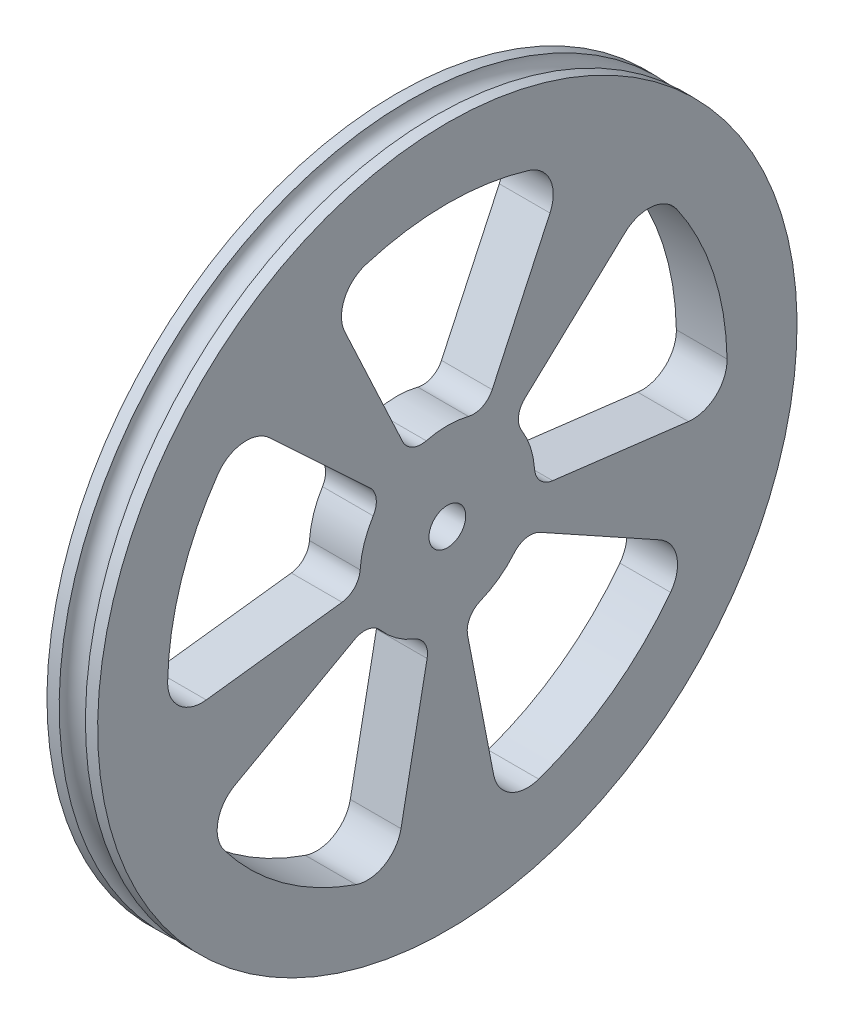
from build123d import *

# Parameters (mm, degrees)
CUT_EXTRUDE1_DEPTH = 8.366
FILLET1_R          = 5
FILLET2_R          = 5
FILLET3_R          = 5
FILLET4_R          = 5
FILLET5_R          = 5
FILLET6_R          = 5
FILLET7_R          = 5
FILLET8_R          = 5
FILLET9_R          = 5
FILLET10_R         = 5
FILLET11_R         = 3
FILLET12_R         = 3
FILLET13_R         = 3
FILLET14_R         = 3
FILLET15_R         = 3
FILLET16_R         = 3
FILLET17_R         = 3
FILLET18_R         = 3
FILLET19_R         = 3
FILLET20_R         = 3
SKETCH4_R          = 2.667
CUT_EXTRUDE2_DEPTH = 8.366


with BuildPart() as part:
    # Sketch1 → Revolve1 (revolve)
    with BuildSketch(Plane.XY):
        with BuildLine():
            Line((1.905, 50.8), (3.683, 50.8))
            Line((3.683, 50.8), (3.683, 0))
            Line((3.683, 0), (-3.683, 0))
            Line((-3.683, 0), (-3.683, 50.8))
            Line((-3.683, 50.8), (-1.905, 50.8))
            ThreePointArc((-1.905, 50.8), (0, 48.895), (1.905, 50.8))
        make_face()
    revolve(axis=Axis((3.683, 0, 0), (-1, 0, 0)))

    # Sketch2 → Cut-Extrude1 (cut, through all)
    with BuildSketch(Plane(origin=(3.683, 0, 0), x_dir=(0, 0, -1), z_dir=(1, 0, 0))):
        with BuildLine():
            Line((-5.367251924, 11.510108895), (-17.175206157, 36.832348465))
            ThreePointArc((-17.175206157, 36.832348465), (0, 40.64), (17.175206157, 36.832348465))
            Line((17.175206157, 36.832348465), (5.367251924, 11.510108895))
            ThreePointArc((5.367251924, 11.510108895), (0, 12.7), (-5.367251924, 11.510108895))
        make_face()
        with BuildLine():
            Line((9.288192011, 8.661379173), (29.722214434, 27.716413353))
            ThreePointArc((29.722214434, 27.716413353), (38.650936822, 12.558450651), (40.337075603, -4.952770116))
            Line((40.337075603, -4.952770116), (12.605336126, -1.547740661))
            ThreePointArc((12.605336126, -1.547740661), (12.078417757, 3.924515829), (9.288192011, 8.661379173))
        make_face()
        with BuildLine():
            Line((11.107670281, -6.157082177), (35.544544898, -19.702662967))
            ThreePointArc((35.544544898, -19.702662967), (23.887592653, -32.878450651), (7.754477572, -39.893328735))
            Line((7.754477572, -39.893328735), (2.423274241, -12.46666523))
            ThreePointArc((2.423274241, -12.46666523), (7.464872704, -10.274515829), (11.107670281, -6.157082177))
        make_face()
        with BuildLine():
            Line((-2.423274241, -12.46666523), (-7.754477572, -39.893328735))
            ThreePointArc((-7.754477572, -39.893328735), (-23.887592653, -32.878450651), (-35.544544898, -19.702662967))
            Line((-35.544544898, -19.702662967), (-11.107670281, -6.157082177))
            ThreePointArc((-11.107670281, -6.157082177), (-7.464872704, -10.274515829), (-2.423274241, -12.46666523))
        make_face()
        with BuildLine():
            Line((-12.605336126, -1.547740661), (-40.337075603, -4.952770116))
            ThreePointArc((-40.337075603, -4.952770116), (-38.650936822, 12.558450651), (-29.722214434, 27.716413353))
            Line((-29.722214434, 27.716413353), (-9.288192011, 8.661379173))
            ThreePointArc((-9.288192011, 8.661379173), (-12.078417757, 3.924515829), (-12.605336126, -1.547740661))
        make_face()
    extrude(amount=-CUT_EXTRUDE1_DEPTH, mode=Mode.SUBTRACT)

    # Fillet1
    fillet1_edges = [part.edges().sort_by_distance(p)[0] for p in [
        (0, -39.893328735, -7.754477572),
    ]]
    fillet(fillet1_edges, radius=FILLET1_R)

    # Fillet2
    fillet2_edges = [part.edges().sort_by_distance(p)[0] for p in [
        (0, -19.702662967, -35.544544898),
    ]]
    fillet(fillet2_edges, radius=FILLET2_R)

    # Fillet3
    fillet3_edges = [part.edges().sort_by_distance(p)[0] for p in [
        (0, 27.716413353, -29.722214434),
    ]]
    fillet(fillet3_edges, radius=FILLET3_R)

    # Fillet4
    fillet4_edges = [part.edges().sort_by_distance(p)[0] for p in [
        (0, -4.952770116, -40.337075603),
    ]]
    fillet(fillet4_edges, radius=FILLET4_R)

    # Fillet5
    fillet5_edges = [part.edges().sort_by_distance(p)[0] for p in [
        (0, 36.832348465, -17.175206157),
    ]]
    fillet(fillet5_edges, radius=FILLET5_R)

    # Fillet6
    fillet6_edges = [part.edges().sort_by_distance(p)[0] for p in [
        (0, 36.832348465, 17.175206157),
    ]]
    fillet(fillet6_edges, radius=FILLET6_R)

    # Fillet7
    fillet7_edges = [part.edges().sort_by_distance(p)[0] for p in [
        (0, -4.952770116, 40.337075603),
    ]]
    fillet(fillet7_edges, radius=FILLET7_R)

    # Fillet8
    fillet8_edges = [part.edges().sort_by_distance(p)[0] for p in [
        (0, 27.716413353, 29.722214434),
    ]]
    fillet(fillet8_edges, radius=FILLET8_R)

    # Fillet9
    fillet9_edges = [part.edges().sort_by_distance(p)[0] for p in [
        (0, -19.702662967, 35.544544898),
    ]]
    fillet(fillet9_edges, radius=FILLET9_R)

    # Fillet10
    fillet10_edges = [part.edges().sort_by_distance(p)[0] for p in [
        (0, -39.893328735, 7.754477572),
    ]]
    fillet(fillet10_edges, radius=FILLET10_R)

    # Fillet11
    fillet11_edges = [part.edges().sort_by_distance(p)[0] for p in [
        (0, 11.510108895, 5.367251924),
    ]]
    fillet(fillet11_edges, radius=FILLET11_R)

    # Fillet12
    fillet12_edges = [part.edges().sort_by_distance(p)[0] for p in [
        (0, 11.510108895, -5.367251924),
    ]]
    fillet(fillet12_edges, radius=FILLET12_R)

    # Fillet13
    fillet13_edges = [part.edges().sort_by_distance(p)[0] for p in [
        (0, -1.547740661, 12.605336126),
    ]]
    fillet(fillet13_edges, radius=FILLET13_R)

    # Fillet14
    fillet14_edges = [part.edges().sort_by_distance(p)[0] for p in [
        (0, 8.661379173, 9.288192011),
    ]]
    fillet(fillet14_edges, radius=FILLET14_R)

    # Fillet15
    fillet15_edges = [part.edges().sort_by_distance(p)[0] for p in [
        (0, -6.157082177, 11.107670281),
    ]]
    fillet(fillet15_edges, radius=FILLET15_R)

    # Fillet16
    fillet16_edges = [part.edges().sort_by_distance(p)[0] for p in [
        (0, -12.46666523, 2.423274241),
    ]]
    fillet(fillet16_edges, radius=FILLET16_R)

    # Fillet17
    fillet17_edges = [part.edges().sort_by_distance(p)[0] for p in [
        (0, -12.46666523, -2.423274241),
    ]]
    fillet(fillet17_edges, radius=FILLET17_R)

    # Fillet18
    fillet18_edges = [part.edges().sort_by_distance(p)[0] for p in [
        (0, -6.157082177, -11.107670281),
    ]]
    fillet(fillet18_edges, radius=FILLET18_R)

    # Fillet19
    fillet19_edges = [part.edges().sort_by_distance(p)[0] for p in [
        (0, -1.547740661, -12.605336126),
    ]]
    fillet(fillet19_edges, radius=FILLET19_R)

    # Fillet20
    fillet20_edges = [part.edges().sort_by_distance(p)[0] for p in [
        (0, 8.661379173, -9.288192011),
    ]]
    fillet(fillet20_edges, radius=FILLET20_R)

    # Sketch4 → Cut-Extrude2 (cut, through all)
    with BuildSketch(Plane.ZY.offset(3.683)):
        Circle(SKETCH4_R)
    extrude(amount=-CUT_EXTRUDE2_DEPTH, mode=Mode.SUBTRACT)


solid = part.part
